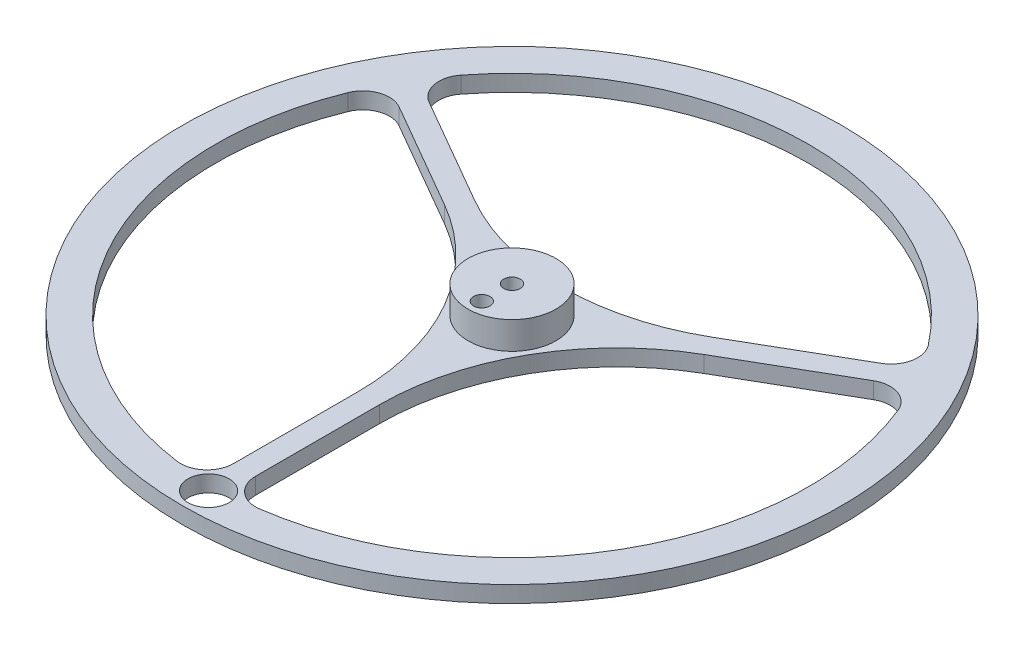
from build123d import *

# Parameters (mm, degrees)
SKETCH1_R           = 60
SKETCH1_R_2         = 54
SKETCH1_R_3         = 8
BOSS_EXTRUDE1_DEPTH = 3
SKETCH1_3_R         = 8
BOSS_EXTRUDE2_DEPTH = 5
CUT_EXTRUDE1_REACH  = 10
SKETCH2_R           = 1.5
CUT_EXTRUDE2_REACH  = 5
SKETCH3_R           = 3.75
SKETCH4_R           = 1.5
CUT_EXTRUDE3_DEPTH  = 5


with BuildPart() as part:
    # Sketch1 → Boss-Extrude1 (new body)
    with BuildSketch(Plane(origin=(0, 0, 0), x_dir=(1, 0, 0), z_dir=(0, 1, 0))):
        Circle(SKETCH1_R)
        Circle(SKETCH1_R_2, mode=Mode.SUBTRACT)
        with BuildLine():
            ThreePointArc((7.5, -53.47663041), (3.660460389, -52.338407931), (2.000000204, -48.694167705))
            Line((2.000000204, -48.694167705), (2.000000204, -26.12435489))
            ThreePointArc((2.000000204, -26.12435489), (3.473664254, -14.930765123), (7.794228634, -4.5))
            ThreePointArc((7.794228634, -4.5), (14.667254021, 4.457101073), (23.624355095, 11.33012646))
            Line((23.624355095, 11.33012646), (43.170386351, 22.615032868))
            ThreePointArc((43.170386351, 22.615032868), (47.156621056, 22.999152279), (50.062120444, 20.243124677))
            ThreePointArc((50.062120444, 20.243124677), (46.765371804, 27), (42.562120444, 33.233505733))
            ThreePointArc((42.562120444, 33.233505733), (43.496160667, 29.339255651), (41.170386147, 26.079134837))
            Line((41.170386147, 26.079134837), (21.62435489, 14.79422843))
            ThreePointArc((21.62435489, 14.79422843), (11.193589767, 10.47366405), (0, 9))
            ThreePointArc((0, 9), (-11.193589767, 10.47366405), (-21.62435489, 14.79422843))
            Line((-21.62435489, 14.79422843), (-41.170386147, 26.079134837))
            ThreePointArc((-41.170386147, 26.079134837), (-43.496160667, 29.339255651), (-42.562120444, 33.233505733))
            ThreePointArc((-42.562120444, 33.233505733), (-46.765371804, 27), (-50.062120444, 20.243124677))
            ThreePointArc((-50.062120444, 20.243124677), (-47.156621056, 22.999152279), (-43.170386351, 22.615032868))
            Line((-43.170386351, 22.615032868), (-23.624355095, 11.33012646))
            ThreePointArc((-23.624355095, 11.33012646), (-14.667254021, 4.457101073), (-7.794228634, -4.5))
            ThreePointArc((-7.794228634, -4.5), (-3.473664254, -14.930765123), (-2.000000204, -26.12435489))
            Line((-2.000000204, -26.12435489), (-2.000000204, -48.694167705))
            ThreePointArc((-2.000000204, -48.694167705), (-3.660460389, -52.338407931), (-7.5, -53.47663041))
            ThreePointArc((-7.5, -53.47663041), (0, -54), (7.5, -53.47663041))
        make_face()
        Circle(SKETCH1_R_3, mode=Mode.SUBTRACT)
        Circle(SKETCH1_R_3)
    extrude(amount=-BOSS_EXTRUDE1_DEPTH)

    # Sketch1_3 → Boss-Extrude2 (add)
    with BuildSketch(Plane(origin=(0, 0, 0), x_dir=(1, 0, 0), z_dir=(0, 1, 0))):
        Circle(SKETCH1_3_R)
    extrude(amount=BOSS_EXTRUDE2_DEPTH)

    # Sketch2 → Cut-Extrude1 (cut, up to next)
    with BuildSketch(Plane(origin=(0, 5, 0), x_dir=(1, 0, 0), z_dir=(0, 1, 0)), mode=Mode.PRIVATE) as cut_extrude1_sk1:
        Circle(SKETCH2_R)
    cut_extrude1_tool1 = extrude(cut_extrude1_sk1.sketch, amount=-CUT_EXTRUDE1_REACH, mode=Mode.PRIVATE) & part.part
    add(cut_extrude1_tool1.solids().sort_by_distance((0, 5, 0))[0], mode=Mode.SUBTRACT)

    # Sketch3 → Cut-Extrude2 (cut, up to next)
    with BuildSketch(Plane(origin=(0, 0, 0), x_dir=(1, 0, 0), z_dir=(0, 1, 0)), mode=Mode.PRIVATE) as cut_extrude2_sk1:
        with Locations((0, -55.25)):
            Circle(SKETCH3_R)
    cut_extrude2_tool1 = extrude(cut_extrude2_sk1.sketch, amount=-CUT_EXTRUDE2_REACH, mode=Mode.PRIVATE) & part.part
    add(cut_extrude2_tool1.solids().sort_by_distance((0, 0, 55.25))[0], mode=Mode.SUBTRACT)

    # Sketch4 → Cut-Extrude3 (cut)
    with BuildSketch(Plane(origin=(0, 5, 0), x_dir=(1, 0, 0), z_dir=(0, 1, 0))):
        with Locations((0, -5.5)):
            Circle(SKETCH4_R)
    extrude(amount=-CUT_EXTRUDE3_DEPTH, mode=Mode.SUBTRACT)


solid = part.part
